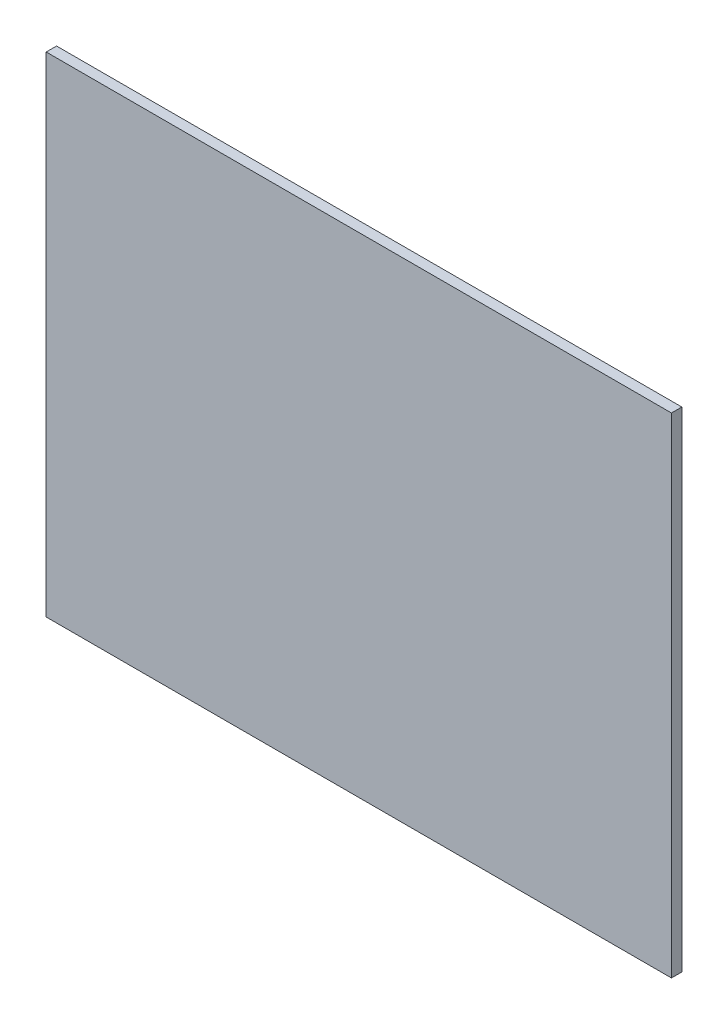
from build123d import *

# Parameters (mm, degrees)
SKETCH1_W           = 1150
SKETCH1_H           = 900
BOSS_EXTRUDE1_DEPTH = 19.05


with BuildPart() as part:
    # Sketch1 → Boss-Extrude1 (new body)
    with BuildSketch(Plane.XY):
        with Locations((575, -450)):
            Rectangle(SKETCH1_W, SKETCH1_H)
    extrude(amount=BOSS_EXTRUDE1_DEPTH)


solid = part.part
